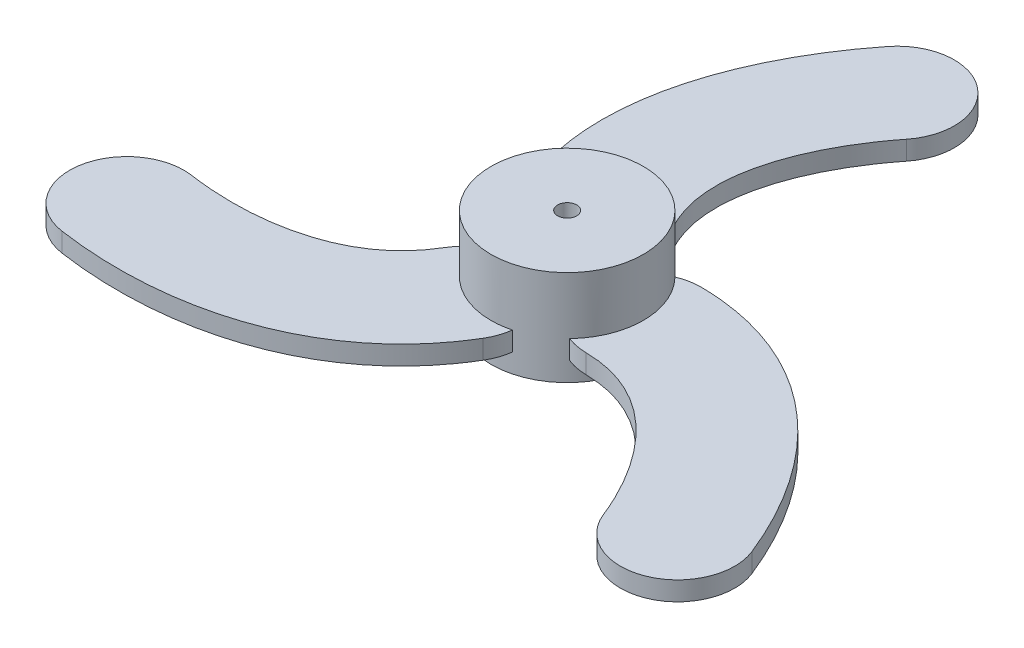
from build123d import *

# Parameters (mm, degrees)
SKETCH1_R               = 4
BOSS_EXTRUDE1_DEPTH     = 5
BOSS_EXTRUDE2_START     = 1
BOSS_EXTRUDE2_DEPTH     = 1
SKETCH3_R               = 0.5
CUT_EXTRUDE1_DEPTH      = 1
CUT_EXTRUDE1_DEPTH_BACK = 6


with BuildPart() as part:
    # Sketch1 → Boss-Extrude1 (new body)
    with BuildSketch(Plane(origin=(0, 0, 0), x_dir=(1, 0, 0), z_dir=(0, 1, 0))):
        Circle(SKETCH1_R)
    extrude(amount=BOSS_EXTRUDE1_DEPTH)

    # Sketch2 → Boss-Extrude2 (add)
    with BuildSketch(Plane(origin=(0, 0, 0), x_dir=(1, 0, 0), z_dir=(0, 1, 0)).offset(BOSS_EXTRUDE2_START)):
        with BuildLine():
            ThreePointArc((3.96292251, -2.970932025), (3.419315306, -2.914444777), (2.894976906, -2.760273305))
            ThreePointArc((2.894976906, -2.760273305), (3.99989603, 0.028840126), (2.854873637, 2.801730986))
            ThreePointArc((2.854873637, 2.801730986), (3.434376926, 2.975056029), (4.036869549, 3.028612277))
            add(Edge.make_bspline(
                [(4.036869549, 3.028612277), (4.461696183, 3.023376101), (5.318698227, 2.968686223), (6.954159562, 2.692039011), (9.640789789, 1.796530328), (12.810078972, -0.41937164), (15.116309585, -3.289140753), (16.531628152, -5.76825703), (17.095168614, -7.020174314), (17.350686676, -7.663372062)],
                knots=[0, 0, 0, 0, 0.0625, 0.125, 0.25, 0.5, 0.75, 0.875, 1, 1, 1, 1], degree=3))
            ThreePointArc((17.350686676, -7.663372062), (15.67022042, -11.559014905), (11.774577577, -9.878548648))
            add(Edge.make_bspline(
                [(3.96292251, -2.970932025), (4.182230159, -2.973635089), (4.62835587, -3.002140243), (5.450410806, -3.141998702), (6.419949985, -3.462832618), (7.519073058, -4.074722518), (8.911985554, -5.187495456), (10.473170644, -7.100700539), (11.40121591, -8.938711436), (11.774577577, -9.878548648)],
                knots=[0, 0, 0, 0, 0.0625, 0.125, 0.25, 0.375, 0.5, 0.75, 1, 1, 1, 1], degree=3))
        make_face()
        with BuildLine():
            ThreePointArc((-3.837955256, -1.126986891), (-1.974971733, -3.478431637), (0.99893339, -3.873258587))
            ThreePointArc((0.99893339, -3.873258587), (0.859285635, -4.461785679), (0.604420396, -5.01033772))
            add(Edge.make_bspline(
                [(0.604420396, -5.01033772), (0.387472417, -5.375630289), (-0.088391429, -6.090470891), (-1.145705609, -7.368498348), (-3.264553992, -9.247434034), (-6.768225979, -10.884167994), (-10.406634241, -11.446537736), (-13.2612712, -11.432681431), (-14.627233602, -11.294763145), (-15.312018222, -11.194449404)],
                knots=[0, 0, 0, 0, 0.0625, 0.125, 0.25, 0.5, 0.75, 0.875, 1, 1, 1, 1], degree=3))
            ThreePointArc((-15.312018222, -11.194449404), (-17.84551076, -7.791301514), (-14.44236287, -5.257808976))
            add(Edge.make_bspline(
                [(-4.554363861, -1.946525554), (-4.666358608, -2.135100018), (-4.914107651, -2.507203639), (-5.446256097, -3.149194868), (-6.208876009, -3.828423469), (-7.288349743, -4.474347022), (-8.948495624, -5.12425816), (-11.385972373, -5.519681567), (-13.441759135, -5.404386894), (-14.44236287, -5.257808976)],
                knots=[0, 0, 0, 0, 0.0625, 0.125, 0.25, 0.375, 0.5, 0.75, 1, 1, 1, 1], degree=3))
            ThreePointArc((-4.554363861, -1.946525554), (-4.233640868, -1.50399153), (-3.837955256, -1.126986891))
        make_face()
        with BuildLine():
            ThreePointArc((0.94297835, 3.887260196), (-2.024924297, 3.449591511), (-3.853807027, 1.071527601))
            ThreePointArc((-3.853807027, 1.071527601), (-4.293662561, 1.48672965), (-4.641289945, 1.981725443))
            add(Edge.make_bspline(
                [(-4.641289945, 1.981725443), (-4.8491686, 2.352254188), (-5.230306799, 3.121784668), (-5.808453952, 4.676459337), (-6.376235797, 7.450903706), (-6.041852992, 11.303539634), (-4.709675344, 14.735678488), (-3.270356952, 17.200938461), (-2.467935012, 18.314937459), (-2.038668454, 18.857821466)],
                knots=[0, 0, 0, 0, 0.0625, 0.125, 0.25, 0.5, 0.75, 0.875, 1, 1, 1, 1], degree=3))
            ThreePointArc((-2.038668454, 18.857821466), (2.17529034, 19.350316419), (2.667785293, 15.136357624))
            add(Edge.make_bspline(
                [(0.591441352, 4.917457579), (0.484128449, 5.108735107), (0.285751781, 5.509343883), (-0.004154708, 6.29119357), (-0.211073976, 7.291256087), (-0.230723315, 8.54906954), (0.03651007, 10.311753616), (0.912801729, 12.620382105), (2.040543226, 14.34309833), (2.667785293, 15.136357624)],
                knots=[0, 0, 0, 0, 0.0625, 0.125, 0.25, 0.375, 0.5, 0.75, 1, 1, 1, 1], degree=3))
            ThreePointArc((0.591441352, 4.917457579), (0.814325562, 4.418436307), (0.94297835, 3.887260196))
        make_face()
    extrude(amount=BOSS_EXTRUDE2_DEPTH)

    # Sketch3 → Cut-Extrude1 (cut, two sides)
    with BuildSketch(Plane(origin=(0, 5, 0), x_dir=(1, 0, 0), z_dir=(0, 1, 0))) as cut_extrude1_sk:
        Circle(SKETCH3_R)
    extrude(amount=CUT_EXTRUDE1_DEPTH, mode=Mode.SUBTRACT)
    extrude(cut_extrude1_sk.sketch, amount=-CUT_EXTRUDE1_DEPTH_BACK, mode=Mode.SUBTRACT)


solid = part.part
